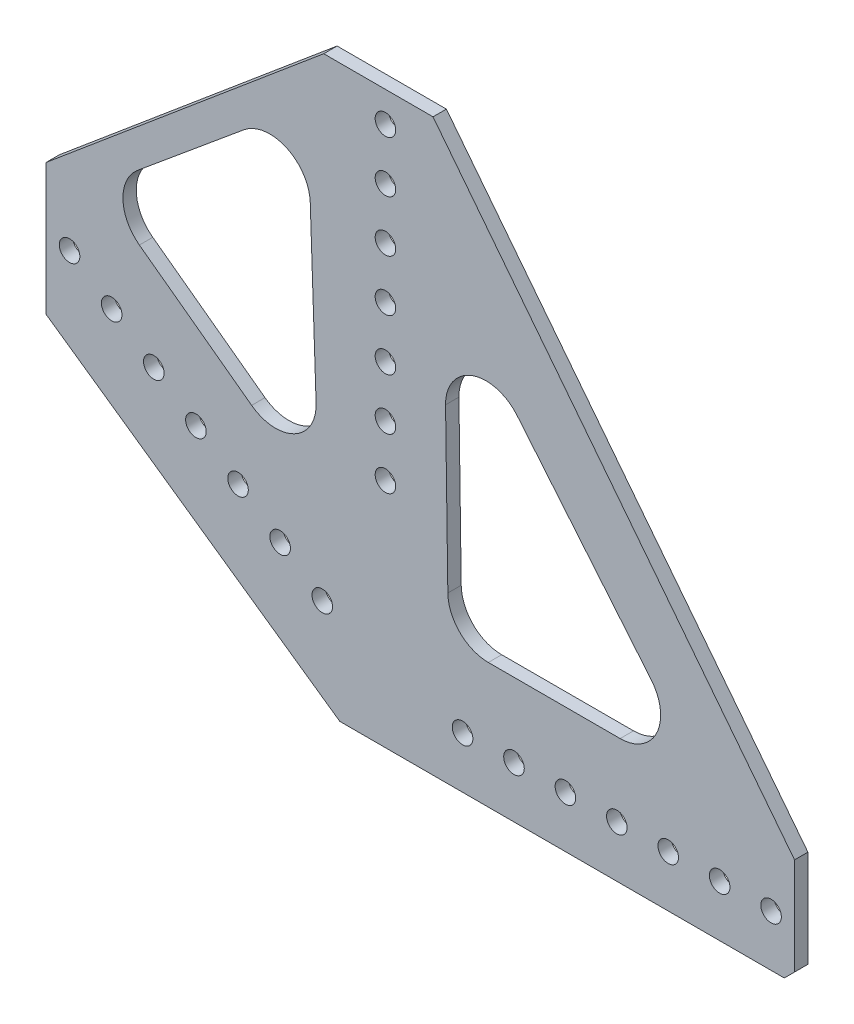
from build123d import *

# Parameters (mm, degrees)
SKETCH1_W           = 25.4
SKETCH1_H           = 90.039220871
SKETCH1_R           = 2.54
SKETCH1_W_2         = 88.349378458
SKETCH1_H_2         = 25.4
BOSS_EXTRUDE3_DEPTH = 3.302
CHAMFER5_SIZE       = 114.3
CHAMFER5_SIZE2      = 89.30094711
CHAMFER6_SIZE       = 50.8
CHAMFER6_SIZE2      = 72.549918742
CHAMFER7_SIZE       = 68.58
CHAMFER7_SIZE2      = 57.545452706
CHAMFER10_SIZE      = 2.54
CUT_EXTRUDE1_DEPTH  = 3.302
FILLET1_R           = 10
FILLET2_R           = 10
FILLET3_R           = 10
FILLET4_R           = 10
FILLET5_R           = 10
FILLET6_R           = 10


with BuildPart() as part:
    # Sketch1 → Boss-Extrude3 (new body)
    with BuildSketch(Plane.XY):
        Polygon((-30.387651704, 9.581189779), (-96.521251531, 55.888434907), (-96.521251531, 0), (0, 0), (0, 25.4), (88.349378458, 25.4), (88.349378458, 140.839220871), (0, 140.839220871), (0, 50.8), (-25.4, 50.8), (-25.4, 140.839220871), (-96.521251531, 140.839220871), (-96.521251531, 86.896109461), (-15.818810221, 30.387651704), align=None)
        with Locations((-12.7, 95.819610436)):
            Rectangle(SKETCH1_W, SKETCH1_H)
        with Locations((-12.7, 57.15)):
            Circle(SKETCH1_R, mode=Mode.SUBTRACT)
        with Locations((-12.7, 69.85)):
            Circle(SKETCH1_R, mode=Mode.SUBTRACT)
        with Locations((-12.7, 82.55)):
            Circle(SKETCH1_R, mode=Mode.SUBTRACT)
        with Locations((-12.7, 95.25)):
            Circle(SKETCH1_R, mode=Mode.SUBTRACT)
        with Locations((-12.7, 107.95)):
            Circle(SKETCH1_R, mode=Mode.SUBTRACT)
        with Locations((-12.7, 120.65)):
            Circle(SKETCH1_R, mode=Mode.SUBTRACT)
        with Locations((-12.7, 133.35)):
            Circle(SKETCH1_R, mode=Mode.SUBTRACT)
        Polygon((-96.521251531, 86.896109461), (-96.521251531, 55.888434907), (-30.387651704, 9.581189779), (-15.818810221, 30.387651704), align=None)
        with Locations((-38.708077406, 30.911051854)):
            Circle(SKETCH1_R, mode=Mode.SUBTRACT)
        with Locations((-28.304846444, 23.626631112)):
            Circle(SKETCH1_R, mode=Mode.SUBTRACT)
        with Locations((-49.111308369, 38.195472596)):
            Circle(SKETCH1_R, mode=Mode.SUBTRACT)
        with Locations((-59.514539331, 45.479893337)):
            Circle(SKETCH1_R, mode=Mode.SUBTRACT)
        with Locations((-69.917770294, 52.764314079)):
            Circle(SKETCH1_R, mode=Mode.SUBTRACT)
        with Locations((-80.321001256, 60.048734821)):
            Circle(SKETCH1_R, mode=Mode.SUBTRACT)
        with Locations((-90.724232219, 67.333155562)):
            Circle(SKETCH1_R, mode=Mode.SUBTRACT)
        with Locations((44.174689229, 12.7)):
            Rectangle(SKETCH1_W_2, SKETCH1_H_2)
        with Locations((6.35, 12.7)):
            Circle(SKETCH1_R, mode=Mode.SUBTRACT)
        with Locations((19.05, 12.7)):
            Circle(SKETCH1_R, mode=Mode.SUBTRACT)
        with Locations((31.75, 12.7)):
            Circle(SKETCH1_R, mode=Mode.SUBTRACT)
        with Locations((44.45, 12.7)):
            Circle(SKETCH1_R, mode=Mode.SUBTRACT)
        with Locations((57.15, 12.7)):
            Circle(SKETCH1_R, mode=Mode.SUBTRACT)
        with Locations((69.85, 12.7)):
            Circle(SKETCH1_R, mode=Mode.SUBTRACT)
        with Locations((82.55, 12.7)):
            Circle(SKETCH1_R, mode=Mode.SUBTRACT)
    extrude(amount=BOSS_EXTRUDE3_DEPTH)

    # Chamfer5
    chamfer5_edges = [part.edges().sort_by_distance(p)[0] for p in [
        (88.349378458, 140.839220871, 1.651),
    ]]
    chamfer5_side = [part.faces().sort_by_distance(p)[0] for p in [
        (88.349378458, 70.419610435, 1.651),
    ]]
    chamfer(chamfer5_edges, length=CHAMFER5_SIZE, length2=CHAMFER5_SIZE2, reference=chamfer5_side[0])

    # Chamfer6
    chamfer6_edges = [part.edges().sort_by_distance(p)[0] for p in [
        (-96.521251531, 0, 1.651),
    ]]
    chamfer6_side = [part.faces().sort_by_distance(p)[0] for p in [
        (-96.521251531, 70.419610435, 1.651),
    ]]
    chamfer(chamfer6_edges, length=CHAMFER6_SIZE, length2=CHAMFER6_SIZE2, reference=chamfer6_side[0])

    # Chamfer7
    chamfer7_edges = [part.edges().sort_by_distance(p)[0] for p in [
        (-96.521251531, 140.839220871, 1.651),
    ]]
    chamfer7_side = [part.faces().sort_by_distance(p)[0] for p in [
        (-48.736410091, 140.839220871, 1.651),
    ]]
    chamfer(chamfer7_edges, length=CHAMFER7_SIZE, length2=CHAMFER7_SIZE2, reference=chamfer7_side[0])

    # Chamfer10
    chamfer10_edges = [part.edges().sort_by_distance(p)[0] for p in [
        (88.349378458, 0, 1.651),
    ]]
    chamfer(chamfer10_edges, length=CHAMFER10_SIZE)

    # Sketch2 → Cut-Extrude1 (cut)
    with BuildSketch(Plane.XY.offset(3.302)):
        Polygon((-31.967710472, 127.732145748), (-83.765850495, 84.732254389), (-29.117573581, 44.458580926), align=None)
        Polygon((1.745305047, 109.142640029), (2.853527199, 30.951410442), (66.547890767, 30.951410442), align=None)
    extrude(amount=-CUT_EXTRUDE1_DEPTH, mode=Mode.SUBTRACT)

    # Fillet1
    fillet1_edges = [part.edges().sort_by_distance(p)[0] for p in [
        (2.853527199, 30.951410442, 1.651),
    ]]
    fillet(fillet1_edges, radius=FILLET1_R)

    # Fillet2
    fillet2_edges = [part.edges().sort_by_distance(p)[0] for p in [
        (-29.117573581, 44.458580926, 1.651),
    ]]
    fillet(fillet2_edges, radius=FILLET2_R)

    # Fillet3
    fillet3_edges = [part.edges().sort_by_distance(p)[0] for p in [
        (66.547890767, 30.951410442, 1.651),
    ]]
    fillet(fillet3_edges, radius=FILLET3_R)

    # Fillet4
    fillet4_edges = [part.edges().sort_by_distance(p)[0] for p in [
        (1.745305047, 109.142640029, 1.651),
    ]]
    fillet(fillet4_edges, radius=FILLET4_R)

    # Fillet5
    fillet5_edges = [part.edges().sort_by_distance(p)[0] for p in [
        (-31.967710472, 127.732145748, 1.651),
    ]]
    fillet(fillet5_edges, radius=FILLET5_R)

    # Fillet6
    fillet6_edges = [part.edges().sort_by_distance(p)[0] for p in [
        (-83.765850495, 84.732254389, 1.651),
    ]]
    fillet(fillet6_edges, radius=FILLET6_R)


solid = part.part
